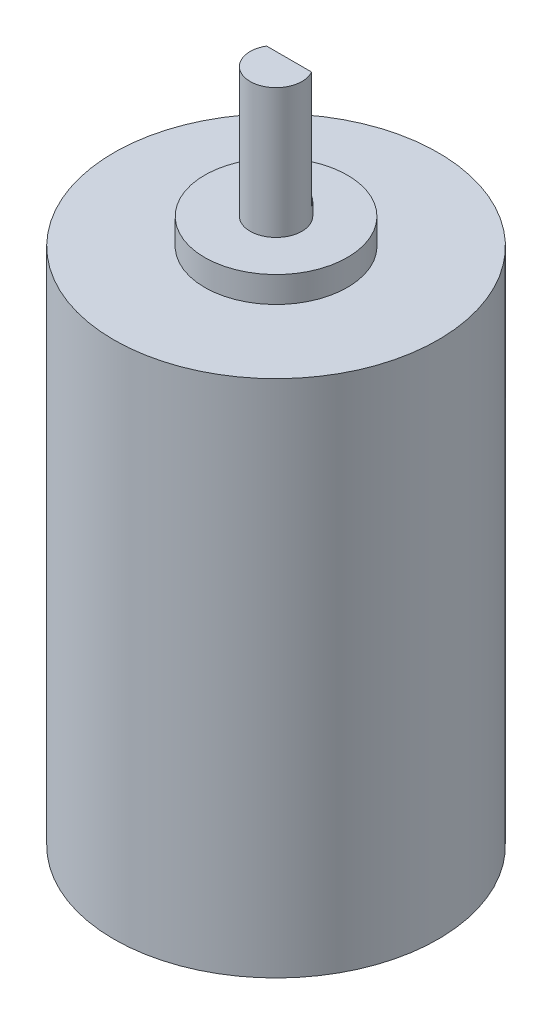
from build123d import *

# Parameters (mm, degrees)
CORTE_EXTRUS_O_FINA1_DEPTH = 9


with BuildPart() as part:
    # Esboço1 → Revolução1 (revolve)
    with BuildSketch(Plane.XY):
        Polygon((0, 0), (12.5, 0), (12.5, 40), (5.5, 40), (5.5, 42), (2, 42), (2, 52), (0, 52), align=None)
    revolve(axis=Axis((0, 52, 0), (0, -1, 0)))

    # Esboço2 → Corte-Extrusão-Fina1 (cut)
    with BuildSketch(Plane(origin=(0, 52, 0), x_dir=(1, 0, 0), z_dir=(0, 1, 0))):
        with BuildLine():
            Line((-4.795831523, 11), (4.795831523, 11))
            ThreePointArc((4.795831523, 11), (0, -12), (-4.795831523, 11))
        make_face()
        with BuildLine():
            Line((-1.732050808, 1), (1.732050808, 1))
            ThreePointArc((1.732050808, 1), (0, -2), (-1.732050808, 1))
        make_face(mode=Mode.SUBTRACT)
    extrude(amount=-CORTE_EXTRUS_O_FINA1_DEPTH, mode=Mode.SUBTRACT)


solid = part.part
